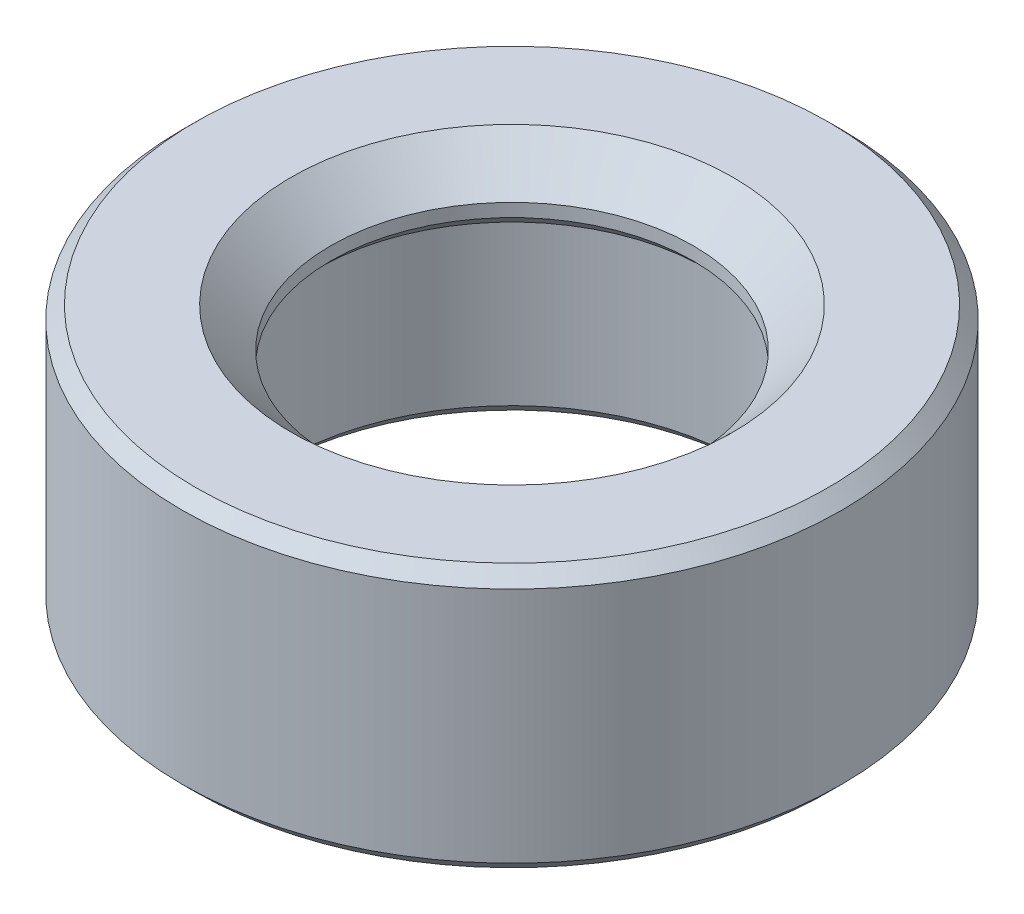
from build123d import *

# Parameters (mm, degrees)
FASE1_SIZE = 0.2
FASE2_SIZE = 0.6


with BuildPart() as part:
    # Skizze1 → Rotation1 (revolve)
    with BuildSketch(Plane(origin=(0, 0, 0), x_dir=(0, 0, -1), z_dir=(1, 0, 0))):
        Polygon((3.5, -2), (3.5, 1), (2.75, 1), (2.75, 2), (5, 2), (5, -2), align=None)
    revolve(axis=Axis((0, 14.193037975, 0), (0, -1, 0)))

    # Fase1
    fase1_edges = [part.edges().sort_by_distance(p)[0] for p in [
        (0, 1, 2.75),
        (0, -2, 3.5),
        (0, -2, 5),
        (0, 2, 5),
    ]]
    chamfer(fase1_edges, length=FASE1_SIZE)

    # Fase2
    fase2_edges = [part.edges().sort_by_distance(p)[0] for p in [
        (0, 2, 2.75),
    ]]
    chamfer(fase2_edges, length=FASE2_SIZE)


solid = part.part
